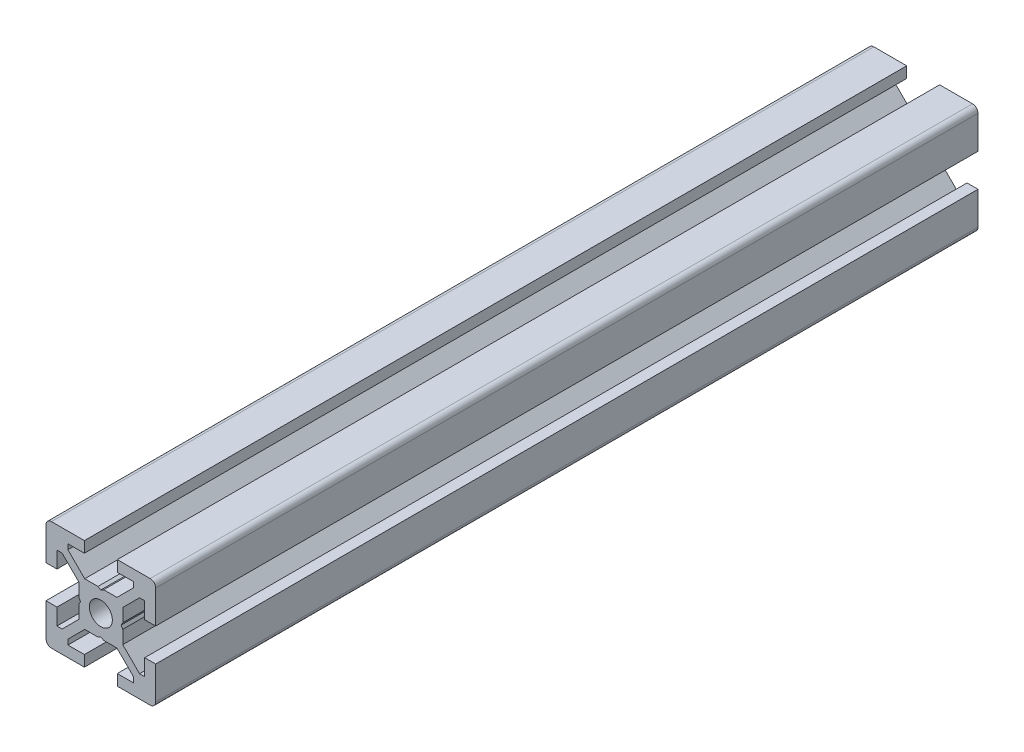
from build123d import *

# Parameters (mm, degrees)
EXTRUDE_1_DEPTH = 150
SKETCH_2_W      = 260
SKETCH_2_H      = 2.1


with BuildPart() as part:
    # ｽｹｯﾁ1 → ﾎﾞｽ - 押し出し1 (new body)
    with BuildSketch(Plane.XY):
        with BuildLine():
            Line((-10, -3), (-10, -9))
            ThreePointArc((-10, -9), (-9.707106781, -9.707106781), (-9, -10))
            Line((-9, -10), (-3, -10))
            Line((-3, -10), (-3, -8))
            Line((-3, -8), (-6, -8))
            Line((-6, -8), (-6, -7.060660172))
            Line((-6, -7.060660172), (-2.939339828, -4))
            Line((-2.939339828, -4), (-0.519615242, -4))
            Line((-0.519615242, -4), (0, -3.7))
            Line((0, -3.7), (0.519615242, -4))
            Line((0.519615242, -4), (2.939339828, -4))
            Line((2.939339828, -4), (6, -7.060660172))
            Line((6, -7.060660172), (6, -8))
            Line((6, -8), (3, -8))
            Line((3, -8), (3, -10))
            Line((3, -10), (9, -10))
            ThreePointArc((9, -10), (9.707106781, -9.707106781), (10, -9))
            Line((10, -9), (10, -3))
            Line((10, -3), (8, -3))
            Line((8, -3), (8, -6))
            Line((8, -6), (7.060660172, -6))
            Line((7.060660172, -6), (4, -2.939339828))
            Line((4, -2.939339828), (4, -0.519615242))
            Line((4, -0.519615242), (3.7, 0))
            Line((3.7, 0), (4, 0.519615242))
            Line((4, 0.519615242), (4, 2.939339828))
            Line((4, 2.939339828), (7.060660172, 6))
            Line((7.060660172, 6), (8, 6))
            Line((8, 6), (8, 3))
            Line((8, 3), (10, 3))
            Line((10, 3), (10, 9))
            ThreePointArc((10, 9), (9.707106781, 9.707106781), (9, 10))
            Line((9, 10), (3, 10))
            Line((3, 10), (3, 8))
            Line((3, 8), (6, 8))
            Line((6, 8), (6, 7.060660172))
            Line((6, 7.060660172), (2.939339828, 4))
            Line((2.939339828, 4), (0.519615242, 4))
            Line((0.519615242, 4), (0, 3.7))
            Line((0, 3.7), (-0.519615242, 4))
            Line((-0.519615242, 4), (-2.939339828, 4))
            Line((-2.939339828, 4), (-6, 7.060660172))
            Line((-6, 7.060660172), (-6, 8))
            Line((-6, 8), (-3, 8))
            Line((-3, 8), (-3, 10))
            Line((-3, 10), (-9, 10))
            ThreePointArc((-9, 10), (-9.707106781, 9.707106781), (-10, 9))
            Line((-10, 9), (-10, 3))
            Line((-10, 3), (-8, 3))
            Line((-8, 3), (-8, 6))
            Line((-8, 6), (-7.060660172, 6))
            Line((-7.060660172, 6), (-4, 2.939339828))
            Line((-4, 2.939339828), (-4, 0.519615242))
            Line((-4, 0.519615242), (-3.7, 0))
            Line((-3.7, 0), (-4, -0.519615242))
            Line((-4, -0.519615242), (-4, -2.939339828))
            Line((-4, -2.939339828), (-7.060660172, -6))
            Line((-7.060660172, -6), (-8, -6))
            Line((-8, -6), (-8, -3))
            Line((-8, -3), (-10, -3))
        make_face()
    extrude(amount=-EXTRUDE_1_DEPTH)

    # ｽｹｯﾁ2 → ｶｯﾄ - 回転1 (revolve, cut)
    with BuildSketch(Plane(origin=(0, 0, 0), x_dir=(0, 0, -1), z_dir=(1, 0, 0))):
        with Locations((130, 1.05)):
            Rectangle(SKETCH_2_W, SKETCH_2_H)
    revolve(axis=Axis((0, 0, -260), (0, 0, 1)), mode=Mode.SUBTRACT)


solid = part.part
